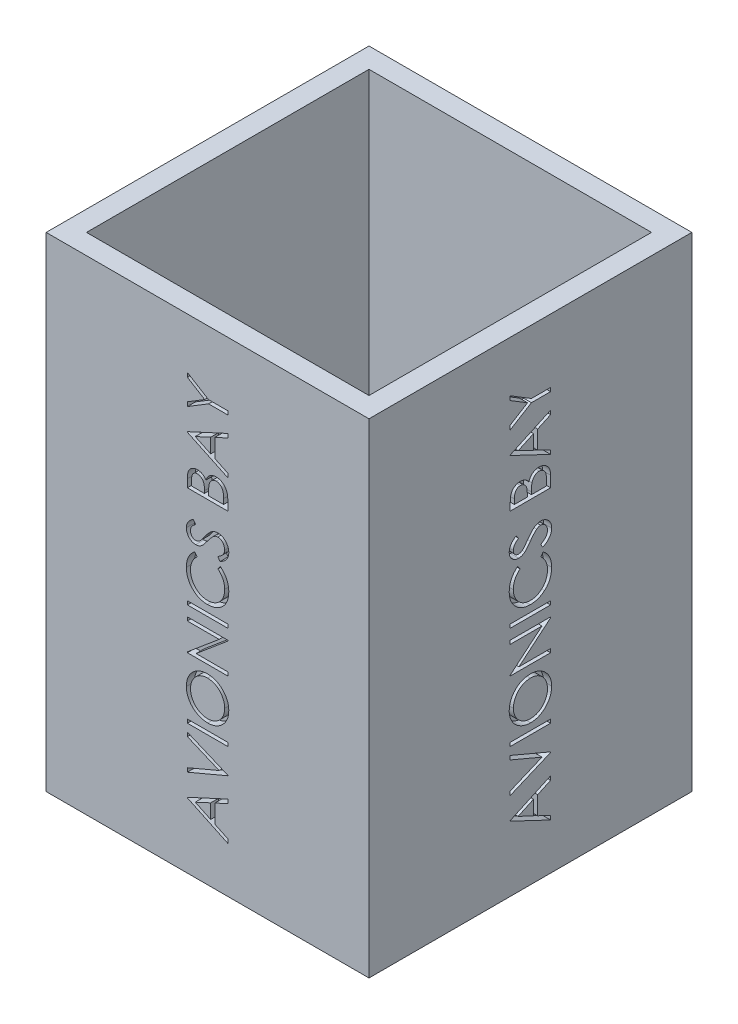
from build123d import *

# Parameters (mm, degrees)
SKETCH1_W           = 101.6
SKETCH1_H           = 101.6
SKETCH1_W_2         = 88.9
SKETCH1_H_2         = 88.9
BOSS_EXTRUDE1_DEPTH = 152.4
SKETCH6_W           = 12.7
SKETCH6_H           = 1.13974359
CUT_EXTRUDE1_DEPTH  = 2.54
CIRPATTERN1_COUNT   = 4


with BuildPart() as part:
    # Sketch1 → Boss-Extrude1 (new body)
    with BuildSketch(Plane(origin=(0, 0, 0), x_dir=(1, 0, 0), z_dir=(0, 1, 0))):
        Rectangle(SKETCH1_W, SKETCH1_H)
        Rectangle(SKETCH1_W_2, SKETCH1_H_2, mode=Mode.SUBTRACT)
    extrude(amount=BOSS_EXTRUDE1_DEPTH)

    # Sketch6 → Cut-Extrude1 (cut)
    with BuildSketch(Plane.ZY.offset(50.8)):
        Polygon((-6.35, 20.678205128), (6.35, 26.53974359), (6.35, 25.30078125), (2.279487179, 23.423257212), (2.279487179, 17.666025641), (6.35, 15.735076122), (6.35, 14.491025641), (-6.35, 20.515384615), align=None)
        Polygon((-3.874619391, 20.584074519), (0.976923077, 18.284234776), (0.976923077, 22.822856571), align=None, mode=Mode.SUBTRACT)
        Polygon((-6.35, 27.516666667), (-6.35, 28.737820513), (3.658373397, 32.971153846), (-6.35, 37.204487179), (-6.35, 38.425641026), (6.35, 33.052564103), (6.35, 32.88974359), align=None)
        with Locations((0, 41.437820513)):
            Rectangle(SKETCH6_W, SKETCH6_H)
        with BuildLine():
            add(Edge.make_bspline(
                [(-6.675641026, 50.718589744), (-6.669785071, 50.953776225), (-6.658283492, 51.415701878), (-6.567334124, 52.093959972), (-6.41764098, 52.74342251), (-6.206242297, 53.364462859), (-5.932190469, 53.954719051), (-5.599295982, 54.515858123), (-5.205535771, 55.046198399), (-4.756691829, 55.542089333), (-4.26513446, 55.994456748), (-3.738912975, 56.391411503), (-3.184643364, 56.726280299), (-2.60229672, 57.000406882), (-1.99323266, 57.215614417), (-1.354037691, 57.364081648), (-0.688898346, 57.458928646), (-0.235229152, 57.47001636), (-0.005088141, 57.475641026)],
                knots=[0, 0, 0, 0, 0.000705368, 0.001385402, 0.0020488, 0.002702076, 0.003349741, 0.00399766, 0.004656078, 0.005327949, 0.006001364, 0.006657226, 0.007302086, 0.007940532, 0.008585026, 0.009236039, 0.009906328, 0.010596447, 0.010596447, 0.010596447, 0.010596447], degree=3))
            add(Edge.make_bspline(
                [(-0.005088141, 57.475641026), (0.223356266, 57.470014467), (0.673646657, 57.458923867), (1.334584132, 57.364004689), (1.969850898, 57.214951949), (2.578031024, 57.003071444), (3.159194899, 56.728734508), (3.71388411, 56.393372735), (4.241511135, 55.997171355), (4.736454933, 55.546724924), (5.189213913, 55.054231132), (5.588564969, 54.530032068), (5.923579539, 53.975777236), (6.200766497, 53.397210358), (6.411489139, 52.78978834), (6.56490218, 52.157931404), (6.658807614, 51.498196983), (6.669968316, 51.048780089), (6.675641026, 50.820352564)],
                knots=[0, 0, 0, 0, 0.000685036, 0.001350284, 0.001998823, 0.002640075, 0.00327852, 0.003923381, 0.004581277, 0.005254856, 0.005928271, 0.006585666, 0.00722835, 0.007867883, 0.008506734, 0.009153393, 0.009816123, 0.010501158, 0.010501158, 0.010501158, 0.010501158], degree=3))
            add(Edge.make_bspline(
                [(6.675641026, 50.820352564), (6.670018965, 50.590212892), (6.658936386, 50.136546337), (6.563935289, 49.470569095), (6.415376844, 48.83093271), (6.203071175, 48.21946635), (5.928688652, 47.635829034), (5.594118477, 47.078879305), (5.19712685, 46.550852685), (4.746579565, 46.056126919), (4.256099934, 45.603465543), (3.730558494, 45.20882438), (3.180265837, 44.874178969), (2.603694821, 44.600717734), (2.003632729, 44.384220981), (1.376076825, 44.236520641), (0.724604903, 44.140958758), (0.281037815, 44.129946601), (0.055969551, 44.124358974)],
                knots=[0, 0, 0, 0, 0.000690119, 0.001360408, 0.002013897, 0.002657552, 0.003298299, 0.003945339, 0.004603236, 0.005276814, 0.005950229, 0.006602529, 0.007245213, 0.007879059, 0.008513962, 0.009155077, 0.009810248, 0.010485118, 0.010485118, 0.010485118, 0.010485118], degree=3))
            add(Edge.make_bspline(
                [(0.055969551, 44.124358974), (-0.095097562, 44.126298937), (-0.395326011, 44.13015439), (-0.841156245, 44.17656996), (-1.279816632, 44.243922419), (-1.710059786, 44.340449359), (-2.130832502, 44.466693407), (-2.545036699, 44.615653621), (-2.948474782, 44.797589631), (-3.343057946, 45.003259411), (-3.722635205, 45.2328094), (-4.081426835, 45.486358548), (-4.422443595, 45.755001171), (-4.736848437, 46.049508342), (-5.033787705, 46.360173729), (-5.308698135, 46.692036987), (-5.564058671, 47.043073131), (-5.794183909, 47.414792623), (-6.002315626, 47.798036078), (-6.180920628, 48.193103243), (-6.33421348, 48.594628516), (-6.45845876, 49.004492525), (-6.556546433, 49.421606869), (-6.623338831, 49.846881916), (-6.669872784, 50.279978863), (-6.673710006, 50.571757077), (-6.675641026, 50.718589744)],
                knots=[0, 0, 0, 0, 0.000453023, 0.000900331, 0.00134327, 0.001783953, 0.002221843, 0.002660465, 0.003103469, 0.003548398, 0.003994743, 0.004433047, 0.004865726, 0.005295975, 0.005724256, 0.006154227, 0.006587795, 0.007025471, 0.007464852, 0.007895214, 0.008325184, 0.00875333, 0.009179133, 0.00960951, 0.010044159, 0.010484467, 0.010484467, 0.010484467, 0.010484467], degree=3))
        make_face()
        with BuildLine():
            add(Edge.make_bspline(
                [(-5.373076923, 50.774559295), (-5.371612874, 50.654036083), (-5.368698771, 50.41414187), (-5.330103131, 50.057532198), (-5.275488499, 49.705504237), (-5.196168901, 49.358739209), (-5.093572448, 49.016509883), (-4.969833028, 48.678664322), (-4.820275395, 48.346360887), (-4.652079665, 48.02001472), (-4.461036223, 47.707163348), (-4.258166746, 47.407053335), (-4.035933534, 47.127490795), (-3.799142721, 46.864635323), (-3.545739327, 46.619140613), (-3.277387483, 46.391114952), (-2.992926494, 46.180745328), (-2.693527038, 45.99056345), (-2.380860728, 45.821316425), (-2.060904396, 45.669782467), (-1.729897889, 45.544166597), (-1.389906788, 45.444660114), (-1.042429358, 45.360201909), (-0.685572416, 45.307223472), (-0.320566176, 45.268247545), (-0.073887757, 45.265494862), (0.05088141, 45.264102564)],
                knots=[0, 0, 0, 0, 0.000361401, 0.000719348, 0.001074863, 0.001429731, 0.001785501, 0.002146095, 0.002508248, 0.002878058, 0.003246738, 0.003607323, 0.00396412, 0.004317168, 0.004668001, 0.005021764, 0.005372855, 0.005728561, 0.006084895, 0.00643885, 0.006789913, 0.007145683, 0.007501125, 0.007861666, 0.008227207, 0.008601324, 0.008601324, 0.008601324, 0.008601324], degree=3))
            add(Edge.make_bspline(
                [(0.05088141, 45.264102564), (0.234345869, 45.268739076), (0.595277215, 45.277860528), (1.124266852, 45.357384132), (1.63314324, 45.480852383), (2.118873279, 45.659858024), (2.583622971, 45.888215042), (3.025583679, 46.166764243), (3.444625029, 46.498056552), (3.837627676, 46.874154181), (4.19619396, 47.285407025), (4.511375607, 47.721887717), (4.776641272, 48.180142983), (4.998397407, 48.657531559), (5.165459253, 49.158129306), (5.284574271, 49.678726583), (5.361776101, 50.219334899), (5.369274234, 50.587728134), (5.373076923, 50.774559295)],
                knots=[0, 0, 0, 0, 0.000550108, 0.001082232, 0.001601154, 0.002118677, 0.00263181, 0.003152009, 0.003682843, 0.004231661, 0.004781633, 0.005317521, 0.005844193, 0.006367833, 0.006893982, 0.007424089, 0.007968455, 0.008528619, 0.008528619, 0.008528619, 0.008528619], degree=3))
            add(Edge.make_bspline(
                [(5.373076923, 50.774559295), (5.371352914, 50.900142838), (5.367933685, 51.149212721), (5.333446658, 51.519666375), (5.278253288, 51.883480379), (5.198393676, 52.23998253), (5.099767851, 52.589639923), (4.97743268, 52.931397518), (4.830782133, 53.265141802), (4.667344949, 53.592513872), (4.481684714, 53.906183548), (4.281550104, 54.204473162), (4.063238117, 54.483554059), (3.829627504, 54.746286203), (3.57700307, 54.99006041), (3.310282099, 55.217436835), (3.025217373, 55.424169109), (2.727044186, 55.613706266), (2.416657403, 55.785018365), (2.095821442, 55.932169161), (1.766257055, 56.057838985), (1.427722103, 56.1591431), (1.080978091, 56.238565908), (0.725528754, 56.293281802), (0.362093818, 56.331558287), (0.116280345, 56.334443183), (-0.007632212, 56.335897436)],
                knots=[0, 0, 0, 0, 0.00037666, 0.00074703, 0.001115112, 0.001479909, 0.001842294, 0.002204411, 0.002567866, 0.002935359, 0.003301431, 0.003660587, 0.004012239, 0.004363588, 0.004714421, 0.005064598, 0.005414184, 0.00576989, 0.006123991, 0.006476875, 0.006827938, 0.007181271, 0.007536139, 0.007894167, 0.008259708, 0.008631282, 0.008631282, 0.008631282, 0.008631282], degree=3))
            add(Edge.make_bspline(
                [(-0.007632212, 56.335897436), (-0.130697041, 56.334441969), (-0.374818801, 56.331554782), (-0.735719484, 56.293300659), (-1.088609709, 56.238506), (-1.432104078, 56.159538459), (-1.766290161, 56.057756476), (-2.090854054, 55.932253863), (-2.407005009, 55.784261543), (-2.713961172, 55.614414362), (-3.008510573, 55.423494815), (-3.290092515, 55.214870151), (-3.553442649, 54.984954519), (-3.804973342, 54.740256746), (-4.03965346, 54.474893764), (-4.256576238, 54.188819264), (-4.465515493, 53.889156128), (-4.650429047, 53.569127694), (-4.822051388, 53.24003162), (-4.968471586, 52.902031491), (-5.094225799, 52.559954443), (-5.196475173, 52.212432789), (-5.275184667, 51.859630794), (-5.330152005, 51.501753628), (-5.368685515, 51.140050484), (-5.371608475, 50.896776301), (-5.373076923, 50.774559295)],
                knots=[0, 0, 0, 0, 0.000369031, 0.00073204, 0.001087555, 0.001439943, 0.001788407, 0.002134718, 0.002482986, 0.00283486, 0.003186283, 0.003535331, 0.003885231, 0.004234241, 0.004587492, 0.004946738, 0.00531086, 0.005682608, 0.006054677, 0.006423813, 0.006786796, 0.007147444, 0.007509758, 0.007870298, 0.008233308, 0.008599795, 0.008599795, 0.008599795, 0.008599795], degree=3))
        make_face(mode=Mode.SUBTRACT)
        Polygon((6.35, 60.080769231), (-6.35, 60.080769231), (-6.35, 60.319911859), (3.645653045, 68.71025641), (-6.35, 68.71025641), (-6.35, 69.85), (6.35, 69.85), (6.35, 69.590504808), (-3.62275641, 61.220512821), (6.35, 61.220512821), align=None)
        with Locations((0, 73.676282051)):
            Rectangle(SKETCH6_W, SKETCH6_H)
        with BuildLine():
            Line((-4.01963141, 88.737179487), (-3.256410256, 87.739903846))
            add(Edge.make_bspline(
                [(-3.256410256, 87.739903846), (-3.341194225, 87.66876175), (-3.509619091, 87.527436708), (-3.746144204, 87.300084035), (-3.96766222, 87.063092265), (-4.175596423, 86.816791141), (-4.361589506, 86.555480687), (-4.540126766, 86.289117567), (-4.696442281, 86.008023627), (-4.887401238, 85.621298238), (-5.082322078, 85.113422851), (-5.249970827, 84.47630071), (-5.355686274, 83.810291597), (-5.36721364, 83.35602053), (-5.373076923, 83.124959936)],
                knots=[0, 0, 0, 0, 0.00033196, 0.000659444, 0.000983431, 0.001304932, 0.001625525, 0.001945168, 0.002266407, 0.002589534, 0.003238685, 0.003894034, 0.004563275, 0.005256052, 0.005256052, 0.005256052, 0.005256052], degree=3))
            add(Edge.make_bspline(
                [(-5.373076923, 83.124959936), (-5.371611116, 82.997657678), (-5.368693107, 82.744234648), (-5.330197138, 82.368138759), (-5.276090748, 81.999065687), (-5.195807431, 81.637255511), (-5.094306788, 81.283168771), (-4.973020274, 80.934490642), (-4.822961328, 80.596269264), (-4.657105476, 80.263826165), (-4.469772216, 79.945312206), (-4.265432984, 79.643944011), (-4.046387468, 79.360803099), (-3.811766703, 79.095730062), (-3.562803693, 78.848216165), (-3.296709232, 78.621376006), (-3.01632795, 78.412178829), (-2.721427006, 78.22181689), (-2.414752947, 78.050446937), (-2.09455485, 77.906351454), (-1.766315152, 77.780499435), (-1.427706865, 77.679347067), (-1.080980558, 77.599905176), (-0.72469984, 77.544982709), (-0.359540199, 77.506932881), (-0.112038264, 77.504028246), (0.012720353, 77.502564103)],
                knots=[0, 0, 0, 0, 0.000381746, 0.00075995, 0.001133062, 0.001500343, 0.001870765, 0.002237676, 0.002606812, 0.002979993, 0.003351741, 0.00371443, 0.004071661, 0.004424911, 0.004775707, 0.005123948, 0.005472996, 0.005824418, 0.006176292, 0.006525803, 0.006876866, 0.007230199, 0.007585067, 0.007943095, 0.008311168, 0.008685285, 0.008685285, 0.008685285, 0.008685285], degree=3))
            add(Edge.make_bspline(
                [(0.012720353, 77.502564103), (0.200426958, 77.507153439), (0.568963978, 77.516163992), (1.108848166, 77.596015543), (1.62655408, 77.718332475), (2.118576381, 77.898650853), (2.58901667, 78.125429822), (3.032169897, 78.408387446), (3.454528385, 78.737342282), (3.845862858, 79.115668985), (4.203321893, 79.530809638), (4.518103914, 79.976206293), (4.780503276, 80.450767193), (4.998856092, 80.949247901), (5.166701906, 81.475485571), (5.284863161, 82.028533553), (5.361941929, 82.607189083), (5.369321311, 83.002592333), (5.373076923, 83.203826122)],
                knots=[0, 0, 0, 0, 0.000562815, 0.001105012, 0.001633818, 0.002156121, 0.002673826, 0.003197534, 0.003730369, 0.00427735, 0.004827582, 0.005371763, 0.005910445, 0.006451621, 0.007001941, 0.007564319, 0.008146516, 0.008749895, 0.008749895, 0.008749895, 0.008749895], degree=3))
            add(Edge.make_bspline(
                [(5.373076923, 83.203826122), (5.366949065, 83.425541593), (5.354887975, 83.86193068), (5.252710128, 84.501894661), (5.087037112, 85.114527297), (4.855178937, 85.699861539), (4.553770606, 86.256247255), (4.188381165, 86.784555137), (3.755534929, 87.285231121), (3.425033292, 87.586298346), (3.256410256, 87.739903846)],
                knots=[0, 0, 0, 0, 0.000664826, 0.001308536, 0.001938654, 0.00256556, 0.003192755, 0.00383282, 0.004489298, 0.005173128, 0.005173128, 0.005173128, 0.005173128], degree=3))
            Line((3.256410256, 87.739903846), (4.011999199, 88.737179487))
            add(Edge.make_bspline(
                [(4.011999199, 88.737179487), (4.115549426, 88.656919532), (4.322153882, 88.496784061), (4.613478666, 88.237535279), (4.887251894, 87.964230312), (5.142106353, 87.676166654), (5.379096924, 87.372836575), (5.598352345, 87.05426791), (5.798709025, 86.720732587), (5.982746472, 86.374879839), (6.144785206, 86.015912717), (6.288375195, 85.646991365), (6.407251844, 85.265853771), (6.507808151, 84.875708271), (6.579509323, 84.473031297), (6.636606518, 84.06250367), (6.670480805, 83.640282994), (6.673905521, 83.355682198), (6.675641026, 83.211458333)],
                knots=[0, 0, 0, 0, 0.00039295, 0.000784017, 0.001168988, 0.001552873, 0.001937104, 0.002323107, 0.002712292, 0.003103781, 0.003497718, 0.003893163, 0.004290641, 0.004694796, 0.005100972, 0.005516895, 0.005937967, 0.006370579, 0.006370579, 0.006370579, 0.006370579], degree=3))
            add(Edge.make_bspline(
                [(6.675641026, 83.211458333), (6.674690367, 83.074865599), (6.672810557, 82.80477038), (6.642358978, 82.40599491), (6.60081279, 82.017775574), (6.538255743, 81.641221932), (6.464434852, 81.274279108), (6.365479149, 80.920273558), (6.254629316, 80.575721795), (6.124345507, 80.242008102), (5.977329645, 79.91884862), (5.811171703, 79.607285647), (5.627268936, 79.307462478), (5.429675042, 79.016431379), (5.212043118, 78.738491576), (4.977395615, 78.471234498), (4.726523405, 78.213161513), (4.545621508, 78.053494627), (4.454667468, 77.973217147)],
                knots=[0, 0, 0, 0, 0.000409666, 0.000810065, 0.001199174, 0.001580615, 0.001954827, 0.00232143, 0.002682661, 0.003040299, 0.003395496, 0.003747176, 0.004098847, 0.004450261, 0.004801913, 0.005157073, 0.005516877, 0.005880706, 0.005880706, 0.005880706, 0.005880706], degree=3))
            add(Edge.make_bspline(
                [(4.454667468, 77.973217147), (4.296671895, 77.844644771), (3.982588209, 77.589052255), (3.473598494, 77.261901295), (2.942643322, 76.982795524), (2.386647308, 76.754609118), (1.80539431, 76.579335337), (1.199819394, 76.456106475), (0.571133136, 76.376587079), (0.143559958, 76.367459908), (-0.073778045, 76.362820513)],
                knots=[0, 0, 0, 0, 0.000610709, 0.001214046, 0.001811469, 0.002408161, 0.003014189, 0.003629886, 0.004260364, 0.004912143, 0.004912143, 0.004912143, 0.004912143], degree=3))
            add(Edge.make_bspline(
                [(-0.073778045, 76.362820513), (-0.302216405, 76.368463644), (-0.751654617, 76.379566151), (-1.41123439, 76.473893752), (-2.04315518, 76.625636241), (-2.646237339, 76.841162094), (-3.223652928, 77.11441294), (-3.770991014, 77.451966653), (-4.291751972, 77.849901712), (-4.77803407, 78.305097172), (-5.222676864, 78.804270075), (-5.613859375, 79.338826914), (-5.93940579, 79.907721407), (-6.211534722, 80.504686183), (-6.420701774, 81.13419137), (-6.567126194, 81.794893881), (-6.658265445, 82.485552229), (-6.669786913, 82.956767316), (-6.675641026, 83.19619391)],
                knots=[0, 0, 0, 0, 0.000685036, 0.001347765, 0.001994424, 0.002631723, 0.003265569, 0.003907406, 0.004557186, 0.005228594, 0.005902557, 0.006560016, 0.007211953, 0.007865497, 0.008525192, 0.009197944, 0.009893113, 0.01061119, 0.01061119, 0.01061119, 0.01061119], degree=3))
            add(Edge.make_bspline(
                [(-6.675641026, 83.19619391), (-6.673890031, 83.342114516), (-6.670424115, 83.630949658), (-6.636678167, 84.058230506), (-6.580304858, 84.474192872), (-6.5039791, 84.879274223), (-6.407862207, 85.27464568), (-6.288069769, 85.659567565), (-6.145448455, 86.033097302), (-5.982581524, 86.395113545), (-5.799438593, 86.743172484), (-5.598179886, 87.077055612), (-5.379822309, 87.395431829), (-5.142130377, 87.696646351), (-4.887075716, 87.981067708), (-4.617645938, 88.252915028), (-4.326927265, 88.504275096), (-4.12225087, 88.659402575), (-4.01963141, 88.737179487)],
                knots=[0, 0, 0, 0, 0.000437698, 0.00086638, 0.001284824, 0.001696468, 0.002102476, 0.00250481, 0.002905006, 0.003301261, 0.003695, 0.004084185, 0.004470188, 0.004852417, 0.005234401, 0.005615774, 0.005999895, 0.006386133, 0.006386133, 0.006386133, 0.006386133], degree=3))
        make_face()
        with BuildLine():
            Line((3.900060096, 90.03974359), (3.256410256, 91.113341346))
            add(Edge.make_bspline(
                [(3.256410256, 91.113341346), (3.423558168, 91.213193236), (3.743807115, 91.404505602), (4.176543433, 91.723643391), (4.544343259, 92.054325669), (4.845066949, 92.399001251), (5.081827195, 92.755566263), (5.249475293, 93.1263484), (5.354036118, 93.510098171), (5.366736432, 93.771260323), (5.373076923, 93.901642628)],
                knots=[0, 0, 0, 0, 0.000583841, 0.001118616, 0.00161028, 0.002064766, 0.002487434, 0.002889373, 0.003281209, 0.003671854, 0.003671854, 0.003671854, 0.003671854], degree=3))
            add(Edge.make_bspline(
                [(5.373076923, 93.901642628), (5.369901903, 94.012969551), (5.363607418, 94.233675437), (5.305569139, 94.559226871), (5.210618635, 94.873820423), (5.081902947, 95.174328835), (4.923683382, 95.452790602), (4.737112822, 95.700890196), (4.521537218, 95.910383999), (4.284942628, 96.084056896), (4.031233879, 96.218443722), (3.769823052, 96.32001459), (3.497123393, 96.376899748), (3.313472359, 96.38543586), (3.220793269, 96.38974359)],
                knots=[0, 0, 0, 0, 0.000333749, 0.000661658, 0.00098843, 0.001317806, 0.001640301, 0.001947123, 0.002245767, 0.002538865, 0.00282455, 0.003104744, 0.003377672, 0.003655722, 0.003655722, 0.003655722, 0.003655722], degree=3))
            add(Edge.make_bspline(
                [(3.220793269, 96.38974359), (3.115018322, 96.384508847), (2.900812519, 96.373907922), (2.584236292, 96.280481264), (2.269594656, 96.137822667), (2.074931876, 96.003739618), (1.974198718, 95.934354968)],
                knots=[0, 0, 0, 0, 0.000316704, 0.000641359, 0.000982872, 0.001349121, 0.001349121, 0.001349121, 0.001349121], degree=3))
            add(Edge.make_bspline(
                [(1.974198718, 95.934354968), (1.90144819, 95.877501361), (1.748717556, 95.758144324), (1.521566328, 95.552774984), (1.286785255, 95.313014926), (1.03922007, 95.042145649), (0.780927013, 94.73971279), (0.5098905, 94.405599338), (0.231649187, 94.036953825), (0.045281334, 93.778202783), (-0.05088141, 93.644691506)],
                knots=[0, 0, 0, 0, 0.00027693, 0.00058138, 0.000917785, 0.001283326, 0.001682064, 0.002110776, 0.002573803, 0.003067412, 0.003067412, 0.003067412, 0.003067412], degree=3))
            add(Edge.make_bspline(
                [(-0.05088141, 93.644691506), (-0.146053714, 93.511073006), (-0.328015911, 93.255604608), (-0.598069742, 92.898340609), (-0.844971783, 92.578864986), (-1.071046341, 92.298597698), (-1.276324078, 92.057662018), (-1.458833743, 91.854159355), (-1.623511235, 91.693273734), (-1.730341247, 91.603809198), (-1.778305288, 91.563641827)],
                knots=[0, 0, 0, 0, 0.000492118, 0.000940893, 0.001343419, 0.001703394, 0.002021005, 0.002292935, 0.002523226, 0.002710868, 0.002710868, 0.002710868, 0.002710868], degree=3))
            add(Edge.make_bspline(
                [(-1.778305288, 91.563641827), (-1.853061333, 91.507508002), (-2.000079127, 91.3971133), (-2.229805018, 91.251233986), (-2.464519473, 91.128213563), (-2.705073148, 91.029205123), (-2.949658139, 90.949140748), (-3.200110695, 90.893475469), (-3.454730594, 90.859164567), (-3.626042223, 90.855620349), (-3.711798878, 90.853846154)],
                knots=[0, 0, 0, 0, 0.000280379, 0.000551403, 0.000815399, 0.001074307, 0.001330956, 0.00158648, 0.001843028, 0.00210018, 0.00210018, 0.00210018, 0.00210018], degree=3))
            add(Edge.make_bspline(
                [(-3.711798878, 90.853846154), (-3.846164323, 90.858581987), (-4.112023245, 90.867952428), (-4.500388447, 90.947205364), (-4.871193366, 91.072281321), (-5.220681509, 91.24756559), (-5.540071901, 91.473310696), (-5.832239357, 91.735689886), (-6.081208535, 92.045304478), (-6.295348186, 92.388070847), (-6.464690808, 92.761284292), (-6.587413997, 93.154196894), (-6.660310029, 93.56398427), (-6.670480481, 93.841990806), (-6.675641026, 93.983052885)],
                knots=[0, 0, 0, 0, 0.000402767, 0.000796926, 0.001183901, 0.001574148, 0.001965141, 0.002354126, 0.002748285, 0.003152792, 0.003563783, 0.00397416, 0.004384892, 0.004807973, 0.004807973, 0.004807973, 0.004807973], degree=3))
            add(Edge.make_bspline(
                [(-6.675641026, 93.983052885), (-6.670549285, 94.132734281), (-6.660423439, 94.430402805), (-6.570190732, 94.867557559), (-6.426581296, 95.290168611), (-6.258089803, 95.628624484), (-6.090878214, 95.894077708), (-5.938243775, 96.096316487), (-5.762888377, 96.302369213), (-5.561115259, 96.510021438), (-5.336960086, 96.72132312), (-5.088525366, 96.935300953), (-4.818049902, 97.153957403), (-4.624912741, 97.294577906), (-4.525901442, 97.366666667)],
                knots=[0, 0, 0, 0, 0.00044863, 0.000892182, 0.001333063, 0.001784748, 0.002022602, 0.002273448, 0.002544149, 0.002833827, 0.003141576, 0.003468021, 0.003817263, 0.004184633, 0.004184633, 0.004184633, 0.004184633], degree=3))
            Line((-4.525901442, 97.366666667), (-3.744871795, 96.336318109))
            add(Edge.make_bspline(
                [(-3.744871795, 96.336318109), (-3.825026824, 96.274107404), (-3.97938667, 96.154304132), (-4.195483741, 95.972345372), (-4.393146913, 95.801104738), (-4.564381231, 95.63110024), (-4.722009393, 95.475435779), (-4.854569572, 95.321670798), (-4.966250039, 95.175739107), (-5.085651319, 94.992234038), (-5.200429634, 94.759775153), (-5.301248892, 94.47040125), (-5.361060256, 94.166971662), (-5.369038173, 93.960416239), (-5.373076923, 93.855849359)],
                knots=[0, 0, 0, 0, 0.000304354, 0.000586115, 0.000847462, 0.001088545, 0.001309821, 0.001511814, 0.001697025, 0.001860738, 0.002167928, 0.002472049, 0.002777898, 0.00309148, 0.00309148, 0.00309148, 0.00309148], degree=3))
            add(Edge.make_bspline(
                [(-5.373076923, 93.855849359), (-5.368752177, 93.724621874), (-5.360412313, 93.471562032), (-5.2669317, 93.11312815), (-5.124800726, 92.788656041), (-4.919849343, 92.510532372), (-4.675507819, 92.280889971), (-4.396853518, 92.112714045), (-4.089090687, 92.012164614), (-3.874507915, 91.999857539), (-3.765224359, 91.993589744)],
                knots=[0, 0, 0, 0, 0.000392785, 0.000757449, 0.001103592, 0.001449623, 0.001786259, 0.002103452, 0.002418835, 0.002746151, 0.002746151, 0.002746151, 0.002746151], degree=3))
            add(Edge.make_bspline(
                [(-3.765224359, 91.993589744), (-3.697198882, 91.995097723), (-3.560200307, 91.998134688), (-3.358759769, 92.036942195), (-3.158381362, 92.089413133), (-2.959770314, 92.169853596), (-2.75842921, 92.281873603), (-2.551514272, 92.428819859), (-2.337243251, 92.613934503), (-2.197879003, 92.755726853), (-2.124298878, 92.830588942)],
                knots=[0, 0, 0, 0, 0.00020378, 0.000410399, 0.000613447, 0.00082462, 0.001051213, 0.001303192, 0.001584654, 0.001899472, 0.001899472, 0.001899472, 0.001899472], degree=3))
            add(Edge.make_bspline(
                [(-2.124298878, 92.830588942), (-2.099490242, 92.858388779), (-2.0405506, 92.924434829), (-1.94405861, 93.045178902), (-1.825031408, 93.204628484), (-1.677757431, 93.3986199), (-1.506918983, 93.630730041), (-1.314700447, 93.90098443), (-1.094861782, 94.206370564), (-0.94116442, 94.423075802), (-0.859895833, 94.537660256)],
                knots=[0, 0, 0, 0, 0.000111766, 0.000265529, 0.000463461, 0.000708709, 0.000996201, 0.001328024, 0.001703617, 0.002125051, 0.002125051, 0.002125051, 0.002125051], degree=3))
            add(Edge.make_bspline(
                [(-0.859895833, 94.537660256), (-0.759597115, 94.675494759), (-0.565382548, 94.942392169), (-0.273589467, 95.322150989), (0.011792861, 95.666475445), (0.28892344, 95.976599914), (0.555762092, 96.255502879), (0.81531225, 96.500372837), (1.06587182, 96.712320821), (1.384920328, 96.943614136), (1.780392633, 97.17715182), (2.265139205, 97.377391189), (2.751276848, 97.504780047), (3.077597552, 97.521324346), (3.238601763, 97.529487179)],
                knots=[0, 0, 0, 0, 0.000511383, 0.000990223, 0.001436481, 0.001852691, 0.002237729, 0.002594081, 0.002922749, 0.003221458, 0.003775598, 0.004295766, 0.004791239, 0.005273789, 0.005273789, 0.005273789, 0.005273789], degree=3))
            add(Edge.make_bspline(
                [(3.238601763, 97.529487179), (3.352459196, 97.527100276), (3.577963027, 97.522372823), (3.909106131, 97.468121419), (4.230644343, 97.388452913), (4.538285192, 97.269341873), (4.836964858, 97.121591781), (5.121056797, 96.936798957), (5.396080303, 96.721480341), (5.654325039, 96.474610946), (5.891685225, 96.204617397), (6.10195552, 95.918225682), (6.281317767, 95.618425471), (6.424162208, 95.301970131), (6.536635166, 94.97225923), (6.617899266, 94.628205505), (6.667829828, 94.269460435), (6.673008226, 94.02561731), (6.675641026, 93.901642628)],
                knots=[0, 0, 0, 0, 0.000341247, 0.000675867, 0.001004131, 0.001333458, 0.001663404, 0.002002138, 0.002348216, 0.002709912, 0.003072253, 0.003425393, 0.003774441, 0.004118267, 0.004465018, 0.004817984, 0.005177419, 0.005549167, 0.005549167, 0.005549167, 0.005549167], degree=3))
            add(Edge.make_bspline(
                [(6.675641026, 93.901642628), (6.673786166, 93.805720098), (6.670099808, 93.615083084), (6.637510594, 93.333108674), (6.591401949, 93.05683075), (6.518198939, 92.789716018), (6.429382315, 92.528323317), (6.320023842, 92.27378834), (6.188967649, 92.025992125), (6.039134719, 91.783529184), (5.864718678, 91.547081161), (5.661754709, 91.318609428), (5.435418335, 91.092103531), (5.182213046, 90.869170227), (4.899354459, 90.654673217), (4.591055869, 90.443463115), (4.256400464, 90.236569246), (4.021058782, 90.106577572), (3.900060096, 90.03974359)],
                knots=[0, 0, 0, 0, 0.00028766, 0.000571697, 0.000850676, 0.001127139, 0.001401486, 0.001678416, 0.001957221, 0.002241725, 0.002532773, 0.002837436, 0.003157645, 0.003492942, 0.003848621, 0.004221915, 0.004613751, 0.005028396, 0.005028396, 0.005028396, 0.005028396], degree=3))
        make_face()
        with BuildLine():
            Line((-6.35, 105.019230769), (-6.35, 107.497155449))
            add(Edge.make_bspline(
                [(-6.35, 107.497155449), (-6.349372317, 107.618454983), (-6.34815571, 107.853563668), (-6.32884905, 108.195419645), (-6.303182672, 108.515726817), (-6.260128703, 108.81391916), (-6.215487417, 109.091936968), (-6.149964695, 109.346957777), (-6.077592462, 109.581117702), (-5.966237959, 109.862295843), (-5.793303013, 110.181330972), (-5.536824054, 110.524234041), (-5.229326494, 110.82230631), (-4.878908769, 111.075756093), (-4.493409562, 111.279154935), (-4.081123013, 111.424443424), (-3.64898535, 111.517782282), (-3.352715027, 111.527260927), (-3.202984776, 111.532051282)],
                knots=[0, 0, 0, 0, 0.000363838, 0.000705208, 0.00102698, 0.001327407, 0.001608892, 0.001871129, 0.002116536, 0.002343771, 0.002777466, 0.0032008, 0.003623583, 0.004057151, 0.004494139, 0.004926249, 0.005365321, 0.005813951, 0.005813951, 0.005813951, 0.005813951], degree=3))
            add(Edge.make_bspline(
                [(-3.202984776, 111.532051282), (-3.062737383, 111.528061266), (-2.787138031, 111.520220508), (-2.384737295, 111.446157844), (-2.002077719, 111.328609812), (-1.639486801, 111.166153689), (-1.303714203, 110.956838065), (-0.995800058, 110.706048525), (-0.727381826, 110.404726897), (-0.577377362, 110.178855189), (-0.501181891, 110.064122596)],
                knots=[0, 0, 0, 0, 0.000420396, 0.000826117, 0.001222837, 0.001619092, 0.002014431, 0.002406622, 0.002806568, 0.003219445, 0.003219445, 0.003219445, 0.003219445], degree=3))
            add(Edge.make_bspline(
                [(-0.501181891, 110.064122596), (-0.445773816, 110.208382216), (-0.339764444, 110.484386606), (-0.152634166, 110.864428018), (0.051636421, 111.190663756), (0.271263785, 111.46946667), (0.511490195, 111.706655781), (0.774267381, 111.912075266), (1.059380217, 112.089664414), (1.365780824, 112.24079155), (1.690871704, 112.3595038), (2.030682193, 112.446755659), (2.383909628, 112.49836703), (2.623616838, 112.505407612), (2.745052083, 112.508974359)],
                knots=[0, 0, 0, 0, 0.000463447, 0.000886689, 0.001268545, 0.0016162, 0.001949007, 0.002278795, 0.002614805, 0.002954998, 0.003301897, 0.00365114, 0.00400589, 0.004370127, 0.004370127, 0.004370127, 0.004370127], degree=3))
            add(Edge.make_bspline(
                [(2.745052083, 112.508974359), (2.869029524, 112.505430578), (3.112958611, 112.49845809), (3.471291465, 112.446993984), (3.813764183, 112.359915894), (4.142434121, 112.239765244), (4.456612174, 112.084030002), (4.755160179, 111.891766128), (5.038699261, 111.665672621), (5.307729832, 111.410150413), (5.553901262, 111.125390902), (5.765525674, 110.811567593), (5.947492508, 110.477277716), (6.095643415, 110.118247692), (6.209941742, 109.735394053), (6.289576238, 109.328929837), (6.343323875, 108.899524432), (6.347736865, 108.604846892), (6.35, 108.453725962)],
                knots=[0, 0, 0, 0, 0.000371861, 0.000731647, 0.001083355, 0.001430255, 0.001779543, 0.002133105, 0.002493475, 0.002865962, 0.003244832, 0.003620227, 0.003999302, 0.004384828, 0.004783241, 0.005195859, 0.005626281, 0.006079382, 0.006079382, 0.006079382, 0.006079382], degree=3))
            Line((6.35, 108.453725962), (6.35, 105.019230769))
            Line((6.35, 105.019230769), (-6.35, 105.019230769))
        make_face()
        with BuildLine():
            Line((-5.047435897, 106.158974359), (-0.976923077, 106.158974359))
            Line((-0.976923077, 106.158974359), (-0.976923077, 106.924739583))
            add(Edge.make_bspline(
                [(-0.976923077, 106.924739583), (-0.978374226, 107.036676641), (-0.981178141, 107.252961848), (-0.989210049, 107.566179755), (-1.011700083, 107.856919118), (-1.034183694, 108.124678018), (-1.070739951, 108.369035007), (-1.114254566, 108.589448052), (-1.160274294, 108.789378525), (-1.238545357, 109.019930907), (-1.354184303, 109.281489371), (-1.533820739, 109.560139099), (-1.747610778, 109.806932087), (-1.996602328, 110.012835745), (-2.267797908, 110.182839956), (-2.558816675, 110.301933252), (-2.863802254, 110.381329207), (-3.073579537, 110.388610711), (-3.180088141, 110.392307692)],
                knots=[0, 0, 0, 0, 0.000335856, 0.000648942, 0.000939679, 0.001210548, 0.001454845, 0.001680365, 0.001884605, 0.002069641, 0.0024101, 0.002739663, 0.003060599, 0.003385683, 0.003705519, 0.004016874, 0.004326007, 0.004644839, 0.004644839, 0.004644839, 0.004644839], degree=3))
            add(Edge.make_bspline(
                [(-3.180088141, 110.392307692), (-3.250585181, 110.390430592), (-3.388872822, 110.386748455), (-3.591119209, 110.355496211), (-3.781156629, 110.304859278), (-3.960808966, 110.236283222), (-4.125611427, 110.142598152), (-4.283438701, 110.034004849), (-4.424837705, 109.899930997), (-4.556615938, 109.748415641), (-4.674557016, 109.57505505), (-4.77225292, 109.376114166), (-4.860797869, 109.156735914), (-4.926345062, 108.910968444), (-4.983983541, 108.64390414), (-5.020198184, 108.351926853), (-5.043502651, 108.036886782), (-5.046095572, 107.818603582), (-5.047435897, 107.705769231)],
                knots=[0, 0, 0, 0, 0.000211403, 0.00041469, 0.000612163, 0.000800665, 0.000989698, 0.001179568, 0.001373986, 0.00157239, 0.001781252, 0.00200084, 0.002236108, 0.002489814, 0.002762742, 0.003055266, 0.00337156, 0.003710008, 0.003710008, 0.003710008, 0.003710008], degree=3))
            Line((-5.047435897, 107.705769231), (-5.047435897, 106.158974359))
        make_face(mode=Mode.SUBTRACT)
        with BuildLine():
            Line((0.325641026, 106.158974359), (5.047435897, 106.158974359))
            Line((5.047435897, 106.158974359), (5.047435897, 107.782091346))
            add(Edge.make_bspline(
                [(5.047435897, 107.782091346), (5.045904986, 107.898262155), (5.042954355, 108.122166073), (5.036034513, 108.445699445), (5.009857802, 108.744782361), (4.985709904, 109.020358318), (4.944418036, 109.271695937), (4.905449249, 109.500728521), (4.847602867, 109.703696342), (4.768099821, 109.941215651), (4.640825315, 110.206707339), (4.454878463, 110.496841966), (4.225391341, 110.749834864), (3.964393202, 110.96700565), (3.681391572, 111.146224413), (3.380086158, 111.274830829), (3.066336778, 111.354751442), (2.852362575, 111.364394611), (2.745052083, 111.369230769)],
                knots=[0, 0, 0, 0, 0.000348575, 0.000671832, 0.000970368, 0.00124908, 0.001501302, 0.001734317, 0.001945399, 0.00213366, 0.002485313, 0.002825429, 0.003164106, 0.003505476, 0.003841486, 0.004165184, 0.004484806, 0.004806367, 0.004806367, 0.004806367, 0.004806367], degree=3))
            add(Edge.make_bspline(
                [(2.745052083, 111.369230769), (2.677946231, 111.368231973), (2.54481695, 111.366250491), (2.34920062, 111.336231529), (2.159617461, 111.292803605), (1.975277451, 111.235607779), (1.799280024, 111.155651098), (1.630950229, 111.057630908), (1.466897116, 110.945429385), (1.256812893, 110.772323658), (1.01776619, 110.516863765), (0.786615655, 110.15382675), (0.597190031, 109.743319967), (0.517108985, 109.444887606), (0.475741186, 109.29072516)],
                knots=[0, 0, 0, 0, 0.000201126, 0.000399009, 0.000592174, 0.000784466, 0.000976909, 0.00117066, 0.001368248, 0.001572487, 0.001986491, 0.00241129, 0.002858707, 0.003336803, 0.003336803, 0.003336803, 0.003336803], degree=3))
            add(Edge.make_bspline(
                [(0.475741186, 109.29072516), (0.463204167, 109.22893387), (0.436021324, 109.094957606), (0.407327657, 108.8764901), (0.381764154, 108.62707709), (0.362855097, 108.34614265), (0.343309639, 108.03333134), (0.33570843, 107.687975093), (0.326639687, 107.311484265), (0.325982428, 107.0502548), (0.325641026, 106.914563301)],
                knots=[0, 0, 0, 0, 0.000189102, 0.000410011, 0.000660625, 0.000941212, 0.001254639, 0.001600782, 0.001977382, 0.002384441, 0.002384441, 0.002384441, 0.002384441], degree=3))
            Line((0.325641026, 106.914563301), (0.325641026, 106.158974359))
        make_face(mode=Mode.SUBTRACT)
        Polygon((-6.35, 120.324358974), (6.35, 126.185897436), (6.35, 124.946935096), (2.279487179, 123.069411058), (2.279487179, 117.312179487), (6.35, 115.381229968), (6.35, 114.137179487), (-6.35, 120.161538462), align=None)
        Polygon((-3.874619391, 120.230228365), (0.976923077, 117.930388622), (0.976923077, 122.469010417), align=None, mode=Mode.SUBTRACT)
        Polygon((-6.35, 127.162820513), (-6.35, 128.467928686), (-0.89296875, 131.805749199), (-6.35, 135.138481571), (-6.35, 136.443589744), (0.312920673, 132.373076923), (6.35, 132.373076923), (6.35, 131.233333333), (0.312920673, 131.233333333), align=None)
    cut_extrude1 = extrude(amount=-CUT_EXTRUDE1_DEPTH, mode=Mode.SUBTRACT)

    # CirPattern1: Cut-Extrude1 ×4 about axis
    cirpattern1_axis = Axis((0, 0, 0), (0, 1, 0))
    for i in range(1, CIRPATTERN1_COUNT):
        add(cut_extrude1.rotate(cirpattern1_axis, i * 360 / CIRPATTERN1_COUNT), mode=Mode.SUBTRACT)


solid = part.part
